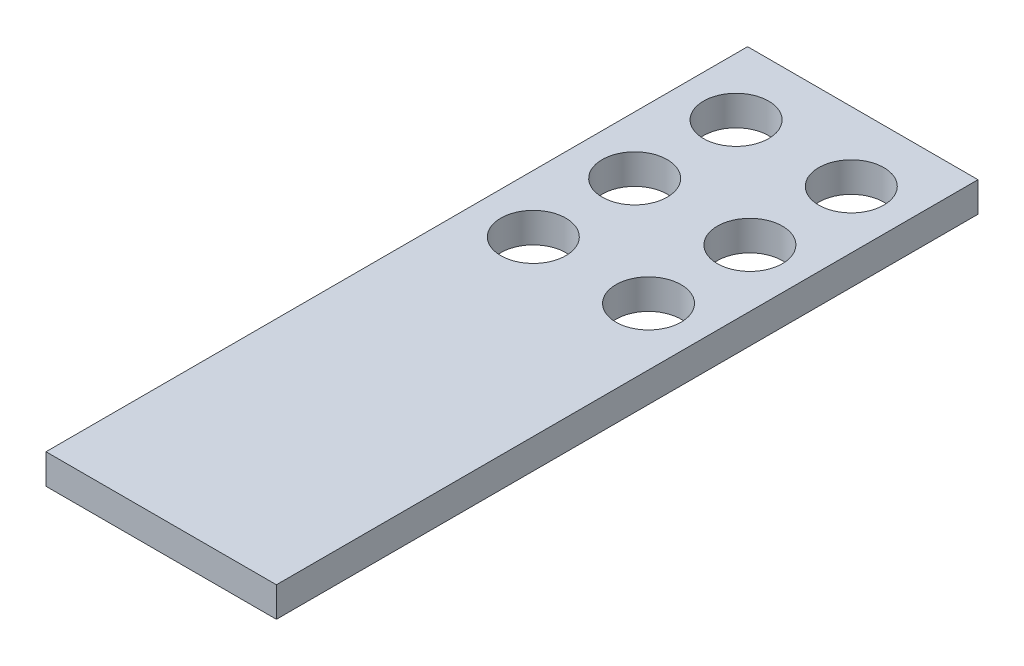
from build123d import *

# Parameters (mm, degrees)
SKETCH1_W           = 200
SKETCH1_H           = 609
SKETCH1_R           = 28.25
BOSS_EXTRUDE1_DEPTH = 26


with BuildPart() as part:
    # Sketch1 → Boss-Extrude1 (new body)
    with BuildSketch(Plane(origin=(0, 0, 0), x_dir=(1, 0, 0), z_dir=(0, 1, 0))):
        with Locations((100, -304.5)):
            Rectangle(SKETCH1_W, SKETCH1_H)
        with Locations((50, -60)):
            Circle(SKETCH1_R, mode=Mode.SUBTRACT)
        with Locations((150, -60)):
            Circle(SKETCH1_R, mode=Mode.SUBTRACT)
        with Locations((50, -148)):
            Circle(SKETCH1_R, mode=Mode.SUBTRACT)
        with Locations((150, -148)):
            Circle(SKETCH1_R, mode=Mode.SUBTRACT)
        with Locations((50, -236)):
            Circle(SKETCH1_R, mode=Mode.SUBTRACT)
        with Locations((150, -236)):
            Circle(SKETCH1_R, mode=Mode.SUBTRACT)
    extrude(amount=BOSS_EXTRUDE1_DEPTH)


solid = part.part
